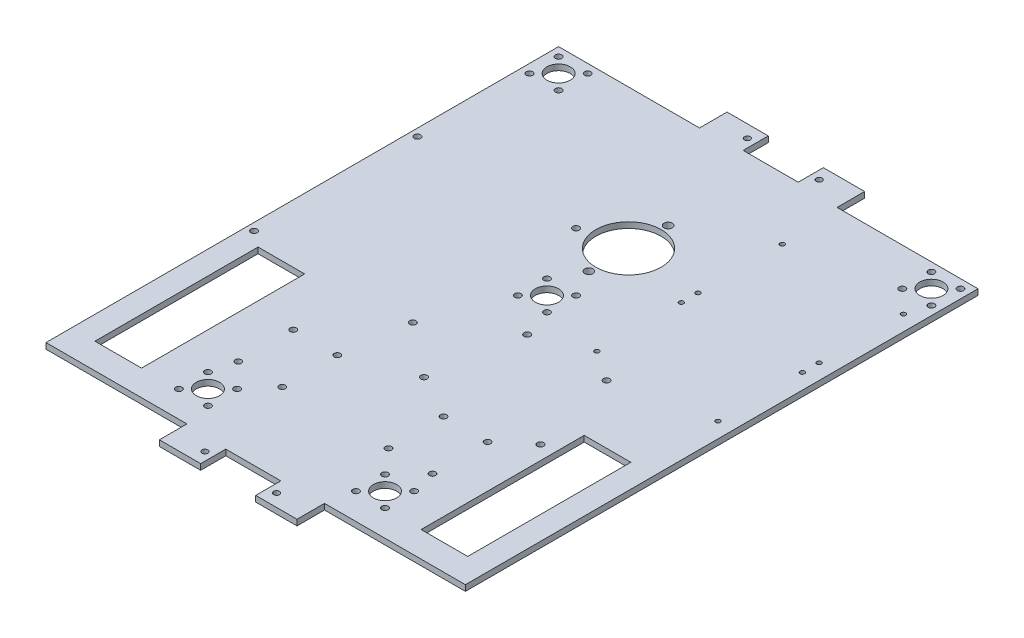
from build123d import *

# Parameters (mm, degrees)
SKETCH1_W               = 228.6
SKETCH1_H               = 279.4
BOSS_EXTRUDE1_DEPTH     = 3.175
SKETCH3_R               = 1.7
SKETCH3_W               = 25.4
SKETCH3_H               = 88.9
CUT_EXTRUDE1_DEPTH      = 4.175
SKETCH4_R               = 17.78
SKETCH4_R_2             = 2.25
CUT_EXTRUDE2_DEPTH      = 4.175
SKETCH5_R               = 1.75
CUT_EXTRUDE3_DEPTH      = 4.175
SKETCH6_R               = 1.25
CUT_EXTRUDE4_DEPTH      = 4.175
SKETCH7_R               = 1.75
CUT_EXTRUDE5_DEPTH      = 4.175
SKETCH8_R               = 1.726999975
SKETCH8_R_2             = 6.35
CUT_EXTRUDE6_DEPTH      = 1
CUT_EXTRUDE6_DEPTH_BACK = 4.175
SKETCH10_W              = 75.000000114
SKETCH10_H              = 14.999999972
BOSS_EXTRUDE2_DEPTH     = 3.175
SKETCH9_R               = 1.599999975
SKETCH9_W               = 29.999999944
SKETCH9_H               = 13.700000032
CUT_EXTRUDE7_DEPTH      = 1
CUT_EXTRUDE7_DEPTH_BACK = 4.175


with BuildPart() as part:
    # Sketch1 → Boss-Extrude1 (new body)
    with BuildSketch(Plane(origin=(0, 0, 0), x_dir=(1, 0, 0), z_dir=(0, 1, 0))):
        with Locations((114.3, 139.7)):
            Rectangle(SKETCH1_W, SKETCH1_H)
    extrude(amount=BOSS_EXTRUDE1_DEPTH)

    # Sketch3 → Cut-Extrude1 (cut, through all)
    with BuildSketch(Plane(origin=(0, 3.175, 0), x_dir=(1, 0, 0), z_dir=(0, 1, 0))):
        with Locations((85.34, 43.42)):
            Circle(SKETCH3_R)
        with Locations((61.34, 43.42)):
            Circle(SKETCH3_R)
        with Locations((85.34, 73.42)):
            Circle(SKETCH3_R)
        with Locations((61.34, 73.42)):
            Circle(SKETCH3_R)
        with Locations((167.26, 73.42)):
            Circle(SKETCH3_R)
        with Locations((143.26, 73.42)):
            Circle(SKETCH3_R)
        with Locations((167.26, 43.42)):
            Circle(SKETCH3_R)
        with Locations((143.26, 43.42)):
            Circle(SKETCH3_R)
        with Locations((203.2, 58.42)):
            Rectangle(SKETCH3_W, SKETCH3_H)
        with Locations((25.4, 58.42)):
            Rectangle(SKETCH3_W, SKETCH3_H)
    extrude(amount=-CUT_EXTRUDE1_DEPTH, mode=Mode.SUBTRACT)

    # Sketch4 → Cut-Extrude2 (cut, through all)
    with BuildSketch(Plane(origin=(0, 3.175, 0), x_dir=(1, 0, 0), z_dir=(0, 1, 0))):
        with Locations((114.3, 203.2)):
            Circle(SKETCH4_R)
        with Locations((114.3, 224.79)):
            Circle(SKETCH4_R_2)
        with Locations((114.3, 181.61)):
            Circle(SKETCH4_R_2)
    extrude(amount=-CUT_EXTRUDE2_DEPTH, mode=Mode.SUBTRACT)

    # Sketch5 → Cut-Extrude3 (cut, through all)
    with BuildSketch(Plane(origin=(0, 3.175, 0), x_dir=(1, 0, 0), z_dir=(0, 1, 0))):
        with Locations((90.5, 198.41)):
            Circle(SKETCH5_R)
        with Locations((90.5, 109.41)):
            Circle(SKETCH5_R)
        with Locations((4, 109.41)):
            Circle(SKETCH5_R)
        with Locations((4, 198.41)):
            Circle(SKETCH5_R)
    extrude(amount=-CUT_EXTRUDE3_DEPTH, mode=Mode.SUBTRACT)

    # Sketch6 → Cut-Extrude4 (cut, through all)
    with BuildSketch(Plane(origin=(0, 3.175, 0), x_dir=(1, 0, 0), z_dir=(0, 1, 0))):
        with Locations((154.25, 247.102093509)):
            Circle(SKETCH6_R)
        with Locations((220.25, 247.102093509)):
            Circle(SKETCH6_R)
        with Locations((220.25, 201.102093509)):
            Circle(SKETCH6_R)
        with Locations((154.25, 201.102093509)):
            Circle(SKETCH6_R)
        with Locations((220.25, 192.022093509)):
            Circle(SKETCH6_R)
        with Locations((220.25, 146.022093509)):
            Circle(SKETCH6_R)
        with Locations((154.25, 146.022093509)):
            Circle(SKETCH6_R)
        with Locations((154.25, 192.022093509)):
            Circle(SKETCH6_R)
    extrude(amount=-CUT_EXTRUDE4_DEPTH, mode=Mode.SUBTRACT)

    # Sketch7 → Cut-Extrude5 (cut, through all)
    with BuildSketch(Plane(origin=(0, 3.175, 0), x_dir=(1, 0, 0), z_dir=(0, 1, 0))):
        with Locations((127.38, 134.915)):
            Circle(SKETCH7_R)
        with Locations((170.62, 134.915)):
            Circle(SKETCH7_R)
        with Locations((119.38, 86.675)):
            Circle(SKETCH7_R)
        with Locations((182.82, 86.675)):
            Circle(SKETCH7_R)
    extrude(amount=-CUT_EXTRUDE5_DEPTH, mode=Mode.SUBTRACT)

    # Sketch8 → Cut-Extrude6 (cut, two sides)
    with BuildSketch(Plane(origin=(0, 3.175, 0), x_dir=(1, 0, 0), z_dir=(0, 1, 0))) as cut_extrude6_sk:
        with Locations((20.63749043, 258.7625)):
            Circle(SKETCH8_R)
        with Locations((4.76249043, 258.7625)):
            Circle(SKETCH8_R)
        with Locations((4.76249043, 274.6375)):
            Circle(SKETCH8_R)
        with Locations((20.63749043, 274.6375)):
            Circle(SKETCH8_R)
        with Locations((12.69999043, 266.7)):
            Circle(SKETCH8_R_2)
        with Locations((58.10249043, 14.2875)):
            Circle(SKETCH8_R)
        with Locations((73.97749043, 14.2875)):
            Circle(SKETCH8_R)
        with Locations((66.03999043, 22.225)):
            Circle(SKETCH8_R_2)
        with Locations((58.10249043, 30.1625)):
            Circle(SKETCH8_R)
        with Locations((73.97749043, 30.1625)):
            Circle(SKETCH8_R)
        with Locations((170.49749043, 14.2875)):
            Circle(SKETCH8_R)
        with Locations((154.62249043, 14.2875)):
            Circle(SKETCH8_R)
        with Locations((154.62249043, 30.1625)):
            Circle(SKETCH8_R)
        with Locations((170.49749043, 30.1625)):
            Circle(SKETCH8_R)
        with Locations((162.55999043, 22.225)):
            Circle(SKETCH8_R_2)
        with Locations((106.36249043, 150.8125)):
            Circle(SKETCH8_R)
        with Locations((122.23749043, 150.8125)):
            Circle(SKETCH8_R)
        with Locations((114.29999043, 158.75)):
            Circle(SKETCH8_R_2)
        with Locations((106.36249043, 166.6875)):
            Circle(SKETCH8_R)
        with Locations((122.23749043, 166.6875)):
            Circle(SKETCH8_R)
        with Locations((223.83749043, 258.7625)):
            Circle(SKETCH8_R)
        with Locations((207.96249043, 258.7625)):
            Circle(SKETCH8_R)
        with Locations((207.96249043, 274.6375)):
            Circle(SKETCH8_R)
        with Locations((223.83749043, 274.6375)):
            Circle(SKETCH8_R)
        with Locations((215.89999043, 266.7)):
            Circle(SKETCH8_R_2)
    extrude(amount=CUT_EXTRUDE6_DEPTH, mode=Mode.SUBTRACT)
    extrude(cut_extrude6_sk.sketch, amount=-CUT_EXTRUDE6_DEPTH_BACK, mode=Mode.SUBTRACT)

    # Sketch10 → Boss-Extrude2 (add)
    with BuildSketch(Plane.XZ):
        with Locations((114.3, 7.499999986)):
            Rectangle(SKETCH10_W, SKETCH10_H)
        with Locations((114.3, -286.899999986)):
            Rectangle(SKETCH10_W, SKETCH10_H)
    extrude(amount=-BOSS_EXTRUDE2_DEPTH)

    # Sketch9 → Cut-Extrude7 (cut, two sides)
    with BuildSketch(Plane(origin=(0, 3.175, 0), x_dir=(1, 0, 0), z_dir=(0, 1, 0))) as cut_extrude7_sk:
        with Locations((133.850000016, 287.549999984)):
            Circle(SKETCH9_R)
        with Locations((94.749999984, 287.549999984)):
            Circle(SKETCH9_R)
        with Locations((133.850000016, -8.149999984)):
            Circle(SKETCH9_R)
        with Locations((94.749999984, -8.149999984)):
            Circle(SKETCH9_R)
        with Locations((114.3, 287.549999984)):
            Rectangle(SKETCH9_W, SKETCH9_H)
        with Locations((114.3, -8.149999984)):
            Rectangle(SKETCH9_W, SKETCH9_H)
    extrude(amount=CUT_EXTRUDE7_DEPTH, mode=Mode.SUBTRACT)
    extrude(cut_extrude7_sk.sketch, amount=-CUT_EXTRUDE7_DEPTH_BACK, mode=Mode.SUBTRACT)


solid = part.part
